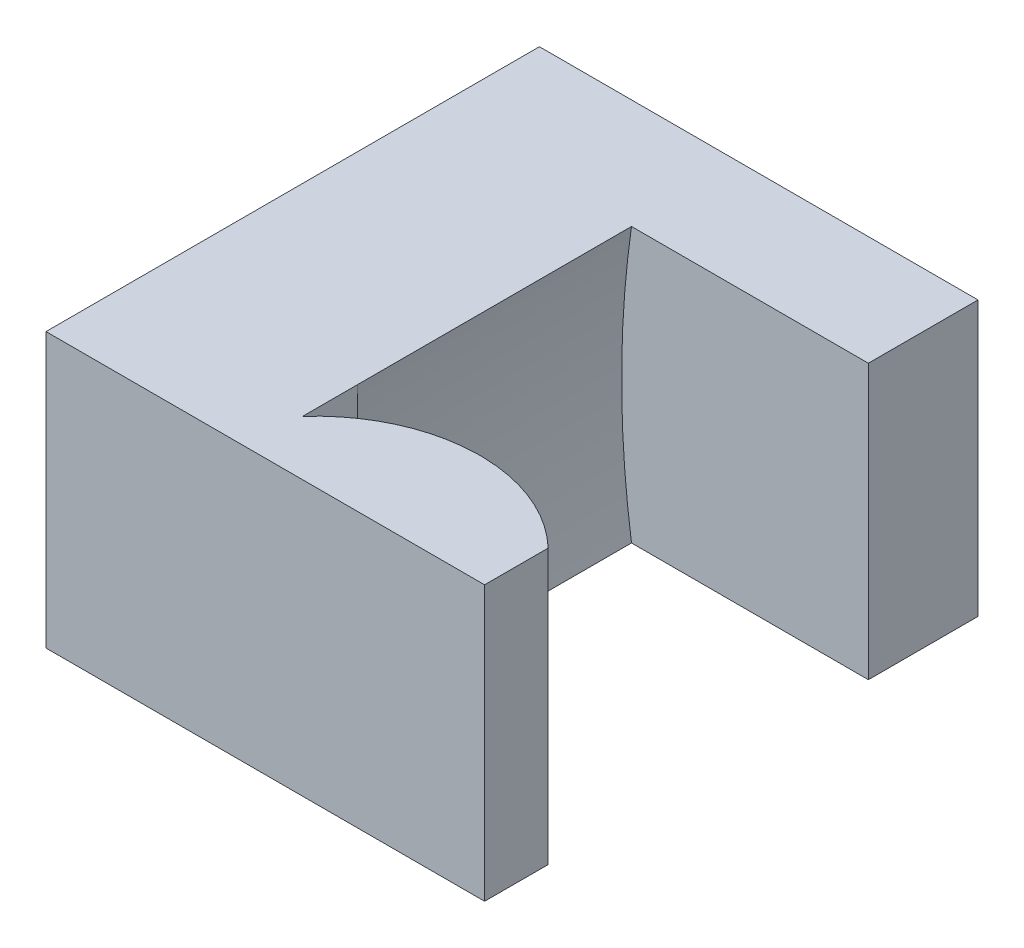
from build123d import *

# Parameters (mm, degrees)
SKETCH1_W               = 8
SKETCH1_H               = 5
BOSS_EXTRUDE1_DEPTH     = 2
BOSS_EXTRUDE2_DEPTH     = 5
BOSS_EXTRUDE5_DEPTH     = 2
CUT_EXTRUDE2_DEPTH      = 1
CUT_EXTRUDE2_DEPTH_BACK = 6


with BuildPart() as part:
    # Sketch1 → Boss-Extrude1 (new body)
    with BuildSketch(Plane.XY):
        with Locations((-17, 0)):
            Rectangle(SKETCH1_W, SKETCH1_H)
    extrude(amount=BOSS_EXTRUDE1_DEPTH)

    # Sketch2 → Boss-Extrude2 (add)
    with BuildSketch(Plane(origin=(0, 0, 0), x_dir=(-1, 0, 0), z_dir=(0, 0, -1))):
        with BuildLine():
            Line((21, 2.5), (17.320508076, 2.5))
            ThreePointArc((17.320508076, 2.5), (17.5, 0), (17.320508076, -2.5))
            Line((17.320508076, -2.5), (21, -2.5))
            Line((21, -2.5), (21, 2.5))
        make_face()
    extrude(amount=BOSS_EXTRUDE2_DEPTH)

    # Sketch3 → Boss-Extrude5 (add)
    with BuildSketch(Plane(origin=(0, 0, -5), x_dir=(-1, 0, 0), z_dir=(0, 0, -1))):
        with BuildLine():
            Line((21, 2.5), (17.320508076, 2.5))
            ThreePointArc((17.320508076, 2.5), (17.5, 0), (17.320508076, -2.5))
            Line((17.320508076, -2.5), (21, -2.5))
            Line((21, -2.5), (21, 2.5))
        make_face()
        with BuildLine():
            Line((17.320508076, 2.5), (13, 2.5))
            Line((13, 2.5), (13, -2.5))
            Line((13, -2.5), (17.320508076, -2.5))
            ThreePointArc((17.320508076, -2.5), (17.5, 0), (17.320508076, 2.5))
        make_face()
    extrude(amount=BOSS_EXTRUDE5_DEPTH)

    # Sketch4 → Cut-Extrude2 (cut, two sides)
    with BuildSketch(Plane(origin=(0, 2.5, 0), x_dir=(1, 0, 0), z_dir=(0, 1, 0))) as cut_extrude2_sk:
        with BuildLine():
            Line((-13, 0), (-15.006873144, 0))
            ThreePointArc((-15.006873144, 0), (-13.924543455, -0.231950336), (-13, -0.840602876))
            Line((-13, -0.840602876), (-13, 0))
        make_face()
        with BuildLine():
            ThreePointArc((-17.320508076, -1), (-16.343812237, -0.276562376), (-15.160254038, 0))
            Line((-15.160254038, 0), (-17.320508076, 0))
            Line((-17.320508076, 0), (-17.320508076, -1))
        make_face()
    extrude(amount=CUT_EXTRUDE2_DEPTH, mode=Mode.SUBTRACT)
    extrude(cut_extrude2_sk.sketch, amount=-CUT_EXTRUDE2_DEPTH_BACK, mode=Mode.SUBTRACT)


solid = part.part
